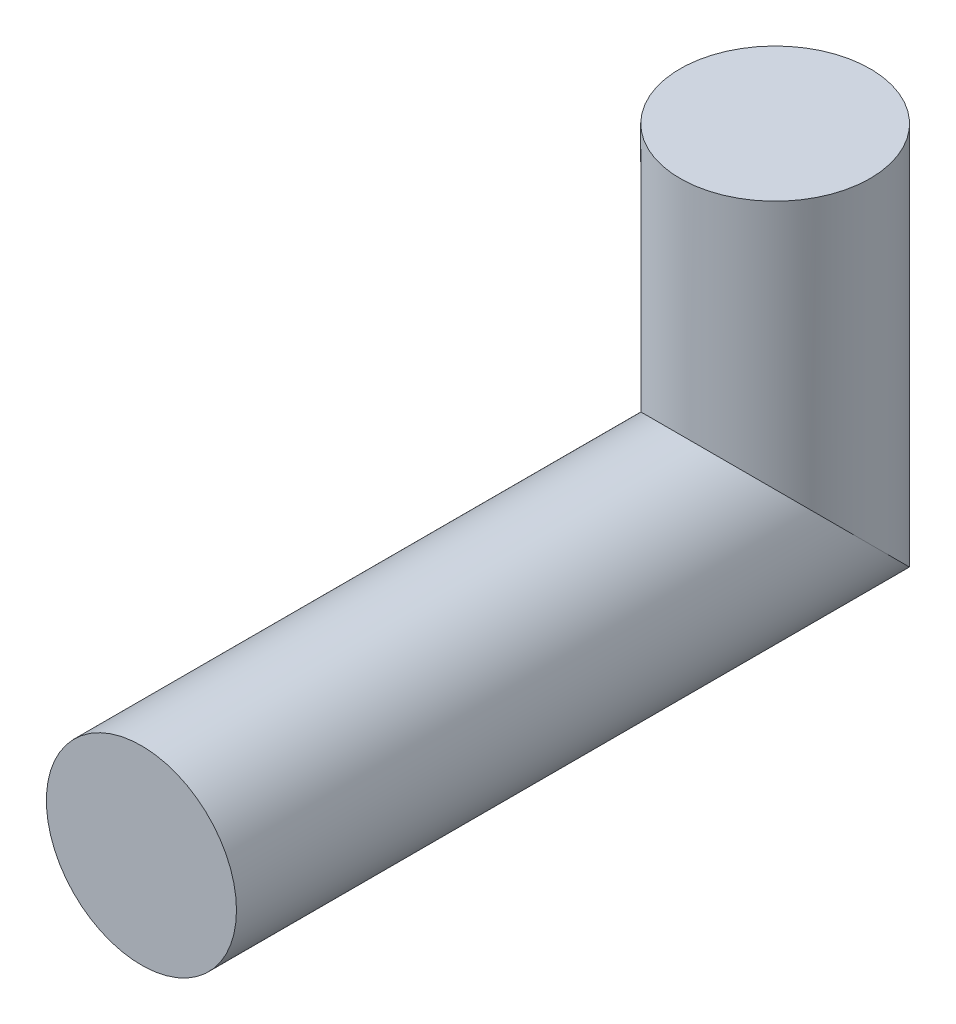
from build123d import *

# Parameters (mm, degrees)
SKETCH1_R = 19.05


with BuildPart() as part:
    # Sweep1: sweep along a path in Sketch2
    with BuildLine(Plane(origin=(0, 0, 0), x_dir=(0, 0, -1), z_dir=(1, 0, 0))) as sweep1_path:
        Line((0, 0), (127, 0))
        Line((127, 0), (127, 63.5))
    # Sketch1 → Sweep1 (sweep)
    with BuildSketch(Plane.XY):
        Circle(SKETCH1_R)
    sweep(path=sweep1_path.line, transition=Transition.RIGHT)


solid = part.part
